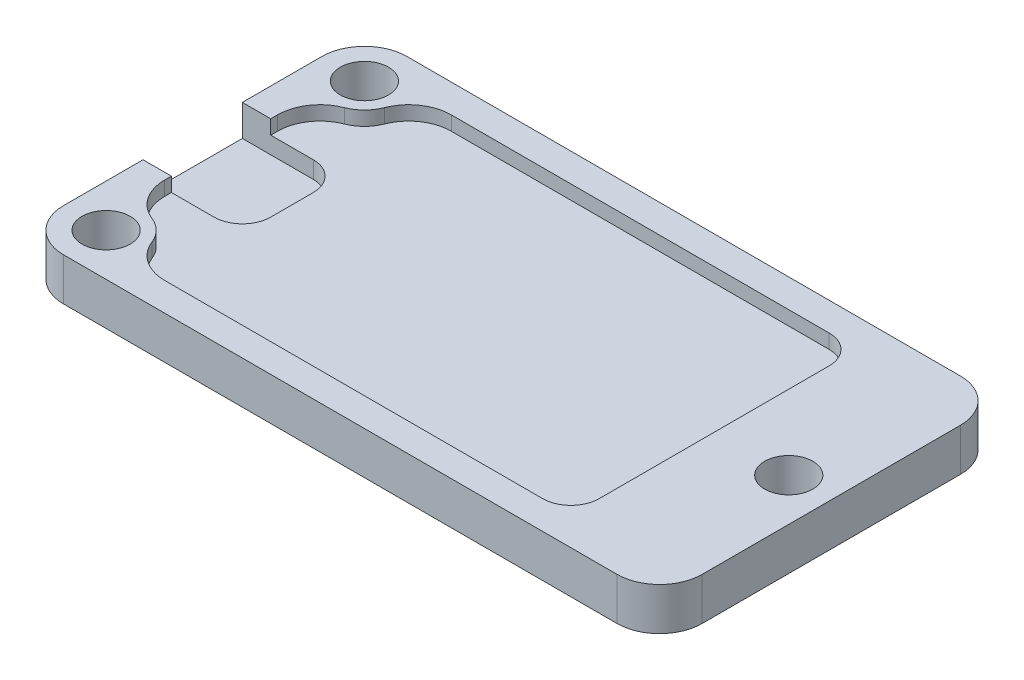
from build123d import *

# Parameters (mm, degrees)
SKETCH_1_W            = 45
SKETCH_1_H            = 24.2
EXTRUDE_1_DEPTH       = 3
FILLET_1_R            = 3
HOLE_WIZARD_M31_D     = 3.4
HOLE_WIZARD_M31_DEPTH = 3
HOLE_WIZARD_M31_TIP   = 1.021463052
CUT_EXTRUDE_1_DEPTH   = 1
FILLET_2_R            = 2
SKETCH_3_W            = 7
SKETCH_3_H            = 7
CUT_EXTRUDE_2_DEPTH   = 2.2
FILLET_3_R            = 2


with BuildPart() as part:
    # Эскиз1 → Бобышка-Вытянуть1 (new body)
    with BuildSketch(Plane(origin=(0, 0, 0), x_dir=(1, 0, 0), z_dir=(0, 1, 0))):
        with Locations((22.5, 12.1)):
            Rectangle(SKETCH_1_W, SKETCH_1_H)
    extrude(amount=EXTRUDE_1_DEPTH)

    # Скругление1
    fillet_1_edges = [part.edges().sort_by_distance(p)[0] for p in [
        (0, 1.5, -24.2),
        (45, 1.5, -24.2),
        (45, 1.5, 0),
        (0, 1.5, 0),
    ]]
    fillet(fillet_1_edges, radius=FILLET_1_R)

    # Отверстие с зазором M31
    with Locations(Plane(origin=(69.423819873, 0, -24.090135757), x_dir=(0, 0, 1), z_dir=(0, -1, 0))):
        with Locations((2.890135757, 66.423819873), (21.090135757, 66.423819873), (11.990135757, 27.423819873)):
            Hole(HOLE_WIZARD_M31_D / 2, depth=HOLE_WIZARD_M31_DEPTH)
            with Locations((0, 0, -(HOLE_WIZARD_M31_DEPTH + HOLE_WIZARD_M31_TIP / 2))):  # 118° drill point
                Cone(0, HOLE_WIZARD_M31_D / 2, HOLE_WIZARD_M31_TIP, mode=Mode.SUBTRACT)

    # Эскиз7 → Вырез-Вытянуть1 (cut)
    with BuildSketch(Plane(origin=(0, 3, 0), x_dir=(1, 0, 0), z_dir=(0, 1, 0))):
        with BuildLine():
            Line((2, 8.123475383), (2, 16.076524617))
            ThreePointArc((2, 16.076524617), (2.522831528, 17.768752841), (3.909090909, 18.871147553))
            ThreePointArc((3.909090909, 18.871147553), (4.767766953, 19.432233047), (5.328852447, 20.290909091))
            ThreePointArc((5.328852447, 20.290909091), (6.431247159, 21.677168472), (8.123475383, 22.2))
            Line((8.123475383, 22.2), (36.752647357, 22.2))
            Line((36.752647357, 22.2), (36.752647357, 2))
            Line((36.752647357, 2), (8.123475383, 2))
            ThreePointArc((8.123475383, 2), (6.431247159, 2.522831528), (5.328852447, 3.909090909))
            ThreePointArc((5.328852447, 3.909090909), (4.767766953, 4.767766953), (3.909090909, 5.328852447))
            ThreePointArc((3.909090909, 5.328852447), (2.522831528, 6.431247159), (2, 8.123475383))
        make_face()
    extrude(amount=-CUT_EXTRUDE_1_DEPTH, mode=Mode.SUBTRACT)

    # Скругление2
    fillet_2_edges = [part.edges().sort_by_distance(p)[0] for p in [
        (36.752647357, 2.5, -22.2),
        (36.752647357, 2.5, -2),
    ]]
    fillet(fillet_2_edges, radius=FILLET_2_R)

    # Эскиз3 → Вырез-Вытянуть2 (cut)
    with BuildSketch(Plane(origin=(0, 3, 0), x_dir=(1, 0, 0), z_dir=(0, 1, 0))):
        with Locations((3.5, 12.1)):
            Rectangle(SKETCH_3_W, SKETCH_3_H)
    extrude(amount=-CUT_EXTRUDE_2_DEPTH, mode=Mode.SUBTRACT)

    # Скругление3
    fillet_3_edges = [part.edges().sort_by_distance(p)[0] for p in [
        (7, 1.4, -8.6),
        (7, 1.4, -15.6),
    ]]
    fillet(fillet_3_edges, radius=FILLET_3_R)


solid = part.part
